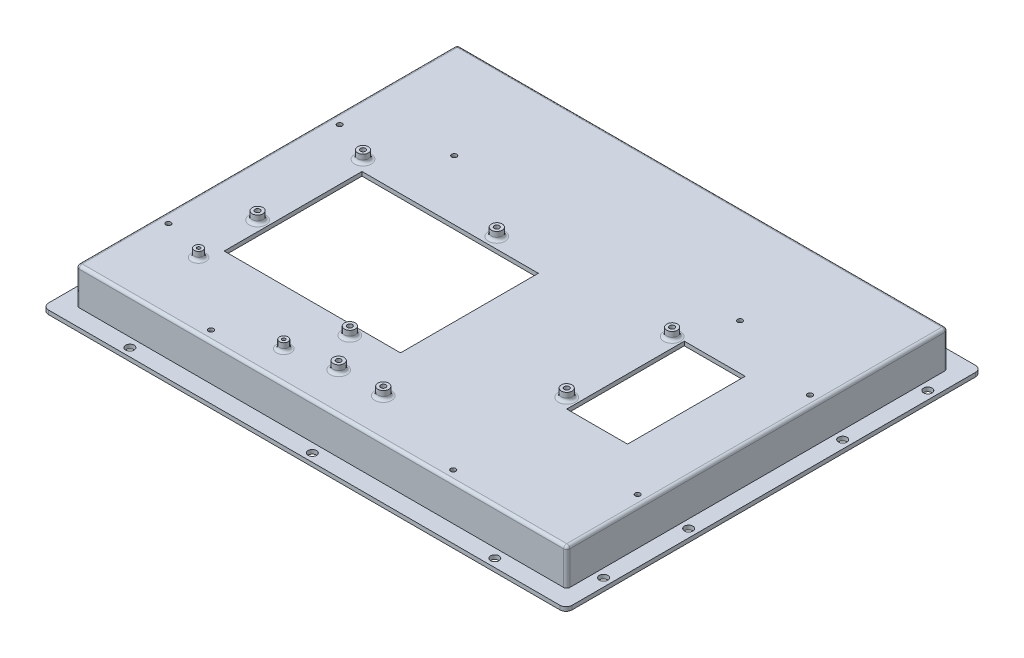
from build123d import *

# Parameters (mm, degrees)
SKETCH1_W                  = 258.3
SKETCH1_H                  = 205
BOSS_EXTRUDE1_DEPTH        = 20
SKETCH2_OUTSIDE_W          = 326.374
SKETCH2_OUTSIDE_H          = 273.074
SKETCH2_OUTSIDE_W_2        = 242
SKETCH2_OUTSIDE_H_2        = 188
CUT_EXTRUDE1_DEPTH         = 18
SKETCH3_W                  = 238
SKETCH3_H                  = 184
CUT_EXTRUDE2_DEPTH         = 18
SKETCH4_W                  = 87
SKETCH4_H                  = 68
SKETCH4_W_2                = 30
SKETCH4_H_2                = 58
CUT_EXTRUDE3_DEPTH         = 21
SKETCH5_R                  = 2.65
BOSS_EXTRUDE2_DEPTH        = 4
SKETCH6_R                  = 1.25
CUT_EXTRUDE4_DEPTH         = 25
SKETCH7_R                  = 2.1
CUT_EXTRUDE5_DEPTH         = 3
SKETCH8_R                  = 1.25
CUT_EXTRUDE6_DEPTH         = 21
SKETCH9_R                  = 3
SKETCH9_R_2                = 1.25
BOSS_EXTRUDE5_DEPTH        = 2
BOSS_EXTRUDE5_DEPTH_BACK   = 1
BOSS_EXTRUDE5_2_DEPTH      = 2
BOSS_EXTRUDE5_2_DEPTH_BACK = 1
BOSS_EXTRUDE5_3_DEPTH      = 2
BOSS_EXTRUDE5_3_DEPTH_BACK = 1
BOSS_EXTRUDE5_4_DEPTH      = 2
BOSS_EXTRUDE5_4_DEPTH_BACK = 1
BOSS_EXTRUDE5_5_DEPTH      = 2
BOSS_EXTRUDE5_5_DEPTH_BACK = 1
BOSS_EXTRUDE5_6_DEPTH      = 2
BOSS_EXTRUDE5_6_DEPTH_BACK = 1
BOSS_EXTRUDE5_7_DEPTH      = 2
BOSS_EXTRUDE5_7_DEPTH_BACK = 1
BOSS_EXTRUDE5_8_DEPTH      = 2
BOSS_EXTRUDE5_8_DEPTH_BACK = 1
SKETCH10_W                 = 12
SKETCH10_H                 = 15
SKETCH10_W_2               = 20
SKETCH10_H_2               = 12
SKETCH10_W_3               = 35
SKETCH10_W_4               = 10
SKETCH10_H_3               = 9.75
BOSS_EXTRUDE6_DEPTH        = 5
SKETCH11_W                 = 241.8
SKETCH11_H                 = 188.8
BOSS_EXTRUDE7_DEPTH        = 2
SKETCH12_W                 = 225
SKETCH12_H                 = 173.5
CUT_EXTRUDE7_DEPTH         = 2
SKETCH13_W                 = 61.997386765
SKETCH13_H                 = 3
SKETCH13_W_2               = 12
CUT_EXTRUDE8_DEPTH         = 0.25
SKETCH14_W                 = 20
SKETCH14_H                 = 3
SKETCH14_W_2               = 12
CUT_EXTRUDE9_DEPTH         = 0.25
SKETCH15_W                 = 5.5
SKETCH15_H                 = 10.3
CUT_EXTRUDE10_DEPTH        = 1.4
SKETCH16_W                 = 8.4
SKETCH16_H                 = 50
CUT_EXTRUDE11_DEPTH        = 2
SKETCH17_R                 = 2.1
BOSS_EXTRUDE8_DEPTH        = 4
SKETCH18_R                 = 0.8
CUT_EXTRUDE12_DEPTH        = 27
SKETCH19_W                 = 225
SKETCH19_H                 = 173.5
CUT_EXTRUDE13_DEPTH        = 1.7
FILLET1_R                  = 1
FILLET2_R                  = 1.5
FILLET3_R                  = 3


with BuildPart() as part:
    # Sketch1 → Boss-Extrude1 (new body)
    with BuildSketch(Plane(origin=(0, 0, 0), x_dir=(1, 0, 0), z_dir=(0, 1, 0))):
        with Locations((129.15, 102.5)):
            Rectangle(SKETCH1_W, SKETCH1_H)
    extrude(amount=BOSS_EXTRUDE1_DEPTH)

    # Sketch2 outside → Cut-Extrude1 (cut)
    with BuildSketch(Plane(origin=(0, 20, 0), x_dir=(-1, 0, 0), z_dir=(0, 1, 0))):
        with Locations((-129.15, -102.5)):
            Rectangle(SKETCH2_OUTSIDE_W, SKETCH2_OUTSIDE_H)
        with Locations((-129.15, -102.5)):
            Rectangle(SKETCH2_OUTSIDE_W_2, SKETCH2_OUTSIDE_H_2, mode=Mode.SUBTRACT)
    extrude(amount=-CUT_EXTRUDE1_DEPTH, mode=Mode.SUBTRACT)

    # Sketch3 → Cut-Extrude2 (cut)
    with BuildSketch(Plane.XZ):
        with Locations((129.15, -102.5)):
            Rectangle(SKETCH3_W, SKETCH3_H)
    extrude(amount=-CUT_EXTRUDE2_DEPTH, mode=Mode.SUBTRACT)

    # Sketch4 → Cut-Extrude3 (cut, through all)
    with BuildSketch(Plane(origin=(0, 20, 0), x_dir=(1, 0, 0), z_dir=(0, 1, 0))):
        with Locations((82.65, 84.5)):
            Rectangle(SKETCH4_W, SKETCH4_H)
        with Locations((206.15, 96.5)):
            Rectangle(SKETCH4_W_2, SKETCH4_H_2)
    extrude(amount=-CUT_EXTRUDE3_DEPTH, mode=Mode.SUBTRACT)

    # Sketch5 → Boss-Extrude2 (add)
    with BuildSketch(Plane(origin=(0, 20, 0), x_dir=(1, 0, 0), z_dir=(0, 1, 0))):
        with Locations((34.15, 72)):
            Circle(SKETCH5_R)
        with Locations((34.15, 124)):
            Circle(SKETCH5_R)
        with Locations((100.15, 124)):
            Circle(SKETCH5_R)
        with Locations((106.15, 45.5)):
            Circle(SKETCH5_R)
        with Locations((186.15, 72.5)):
            Circle(SKETCH5_R)
        with Locations((186.15, 124.5)):
            Circle(SKETCH5_R)
        with Locations((118.15, 28)):
            Circle(SKETCH5_R)
        with Locations((140.15, 28)):
            Circle(SKETCH5_R)
    extrude(amount=BOSS_EXTRUDE2_DEPTH)

    # Sketch6 → Cut-Extrude4 (cut, through all)
    with BuildSketch(Plane(origin=(0, 24, 0), x_dir=(1, 0, 0), z_dir=(0, 1, 0))):
        with Locations((34.15, 124)):
            Circle(SKETCH6_R)
        with Locations((100.15, 124)):
            Circle(SKETCH6_R)
        with Locations((186.15, 124.5)):
            Circle(SKETCH6_R)
        with Locations((186.15, 72.5)):
            Circle(SKETCH6_R)
        with Locations((106.15, 45.5)):
            Circle(SKETCH6_R)
        with Locations((34.15, 72)):
            Circle(SKETCH6_R)
        with Locations((140.15, 28)):
            Circle(SKETCH6_R)
        with Locations((118.15, 28)):
            Circle(SKETCH6_R)
    extrude(amount=-CUT_EXTRUDE4_DEPTH, mode=Mode.SUBTRACT)

    # Sketch7 → Cut-Extrude5 (cut, through all)
    with BuildSketch(Plane(origin=(0, 2, 0), x_dir=(1, 0, 0), z_dir=(0, 1, 0))):
        with Locations((254.3, 22.5)):
            Circle(SKETCH7_R)
        with Locations((254.3, 140.5)):
            Circle(SKETCH7_R)
        with Locations((254.3, 182.5)):
            Circle(SKETCH7_R)
        with Locations((219.15, 201)):
            Circle(SKETCH7_R)
        with Locations((134.15, 201)):
            Circle(SKETCH7_R)
        with Locations((124.15, 201)):
            Circle(SKETCH7_R)
        with Locations((39.15, 201)):
            Circle(SKETCH7_R)
        with Locations((4, 182.5)):
            Circle(SKETCH7_R)
        with Locations((4, 102.5)):
            Circle(SKETCH7_R)
        with Locations((4, 22.5)):
            Circle(SKETCH7_R)
        with Locations((219.15, 4)):
            Circle(SKETCH7_R)
        with Locations((129.15, 4)):
            Circle(SKETCH7_R)
        with Locations((39.15, 4)):
            Circle(SKETCH7_R)
        with Locations((254.3, 64.5)):
            Circle(SKETCH7_R)
    extrude(amount=-CUT_EXTRUDE5_DEPTH, mode=Mode.SUBTRACT)

    # Sketch8 → Cut-Extrude6 (cut, through all)
    with BuildSketch(Plane(origin=(0, 20, 0), x_dir=(1, 0, 0), z_dir=(0, 1, 0))):
        with Locations((55.15, 148)):
            Circle(SKETCH8_R)
        with Locations((13.65, 133)):
            Circle(SKETCH8_R)
        with Locations((13.65, 48.5)):
            Circle(SKETCH8_R)
        with Locations((69.65, 13.5)):
            Circle(SKETCH8_R)
        with Locations((189.15, 13.5)):
            Circle(SKETCH8_R)
        with Locations((245.15, 48.5)):
            Circle(SKETCH8_R)
        with Locations((245.15, 133.5)):
            Circle(SKETCH8_R)
        with Locations((196.15, 148)):
            Circle(SKETCH8_R)
    extrude(amount=-CUT_EXTRUDE6_DEPTH, mode=Mode.SUBTRACT)

    # Sketch10 → Boss-Extrude6 (add)
    with BuildSketch(Plane.XZ):
        with Locations((14.15, -15.75)):
            Rectangle(SKETCH10_W, SKETCH10_H)
        with Locations((129.15, -14.25)):
            Rectangle(SKETCH10_W_2, SKETCH10_H_2)
        with Locations((244.15, -15.75)):
            Rectangle(SKETCH10_W, SKETCH10_H)
        with Locations((14.15, -189.25)):
            Rectangle(SKETCH10_W, SKETCH10_H)
        with Locations((163.65, -190.75)):
            Rectangle(SKETCH10_W_3, SKETCH10_H_2)
        with Locations((244.15, -189.25)):
            Rectangle(SKETCH10_W, SKETCH10_H)
        with Locations((15.15, -67.5)):
            Rectangle(SKETCH10_W_4, SKETCH10_H)
        with Locations((15.15, -137.5)):
            Rectangle(SKETCH10_W_4, SKETCH10_H)
        with Locations((243.15, -67.5)):
            Rectangle(SKETCH10_W_4, SKETCH10_H)
        with Locations((243.15, -137.5)):
            Rectangle(SKETCH10_W_4, SKETCH10_H)
        with Locations((66.65, -15.375)):
            Rectangle(SKETCH10_W_2, SKETCH10_H_3)
        with Locations((191.65, -15.375)):
            Rectangle(SKETCH10_W_2, SKETCH10_H_3)
        with Locations((94.65, -189.625)):
            Rectangle(SKETCH10_W_3, SKETCH10_H_3)
        with Locations((224.15, -189.625)):
            Rectangle(SKETCH10_W, SKETCH10_H_3)
        with Locations((34.15, -189.625)):
            Rectangle(SKETCH10_W, SKETCH10_H_3)
    extrude(amount=-BOSS_EXTRUDE6_DEPTH)

    # Sketch11 → Boss-Extrude7 (add)
    with BuildSketch(Plane.XZ):
        with Locations((129.15, -102.5)):
            Rectangle(SKETCH11_W, SKETCH11_H)
    extrude(amount=BOSS_EXTRUDE7_DEPTH)

    # Sketch12 → Cut-Extrude7 (cut)
    with BuildSketch(Plane.XZ.offset(2)):
        with Locations((129.15, -102.5)):
            Rectangle(SKETCH12_W, SKETCH12_H)
    extrude(amount=-CUT_EXTRUDE7_DEPTH, mode=Mode.SUBTRACT)

    # Sketch13 → Cut-Extrude8 (cut)
    with BuildSketch(Plane(origin=(0, 0, -196.75), x_dir=(-1, 0, 0), z_dir=(0, 0, -1))):
        with Locations((-150.151306618, 3.5)):
            Rectangle(SKETCH13_W, SKETCH13_H)
        with Locations((-14.15, 3.5)):
            Rectangle(SKETCH13_W_2, SKETCH13_H)
        with Locations((-244.15, 3.5)):
            Rectangle(SKETCH13_W_2, SKETCH13_H)
    extrude(amount=-CUT_EXTRUDE8_DEPTH, mode=Mode.SUBTRACT)

    # Sketch14 → Cut-Extrude9 (cut)
    with BuildSketch(Plane.XY.offset(-8.25)):
        with Locations((129.15, 3.5)):
            Rectangle(SKETCH14_W, SKETCH14_H)
        with Locations((244.15, 3.5)):
            Rectangle(SKETCH14_W_2, SKETCH14_H)
        with Locations((14.15, 3.5)):
            Rectangle(SKETCH14_W_2, SKETCH14_H)
    extrude(amount=-CUT_EXTRUDE9_DEPTH, mode=Mode.SUBTRACT)

    # Sketch15 → Cut-Extrude10 (cut)
    with BuildSketch(Plane.XZ.offset(2)):
        with Locations((13.9, -38.9)):
            Rectangle(SKETCH15_W, SKETCH15_H)
        with Locations((13.9, -166.1)):
            Rectangle(SKETCH15_W, SKETCH15_H)
        with Locations((244.4, -166.1)):
            Rectangle(SKETCH15_W, SKETCH15_H)
        with Locations((244.4, -38.9)):
            Rectangle(SKETCH15_W, SKETCH15_H)
    extrude(amount=-CUT_EXTRUDE10_DEPTH, mode=Mode.SUBTRACT)

    # Sketch16 → Cut-Extrude11 (cut)
    with BuildSketch(Plane.XZ.offset(2)):
        with Locations((12.45, -102.5)):
            Rectangle(SKETCH16_W, SKETCH16_H)
    extrude(amount=-CUT_EXTRUDE11_DEPTH, mode=Mode.SUBTRACT)

    # Sketch17 → Boss-Extrude8 (add)
    with BuildSketch(Plane(origin=(0, 20, 0), x_dir=(1, 0, 0), z_dir=(0, 1, 0))):
        with Locations((35.55, 41.5)):
            Circle(SKETCH17_R)
        with Locations((95.55, 23.5)):
            Circle(SKETCH17_R)
    extrude(amount=BOSS_EXTRUDE8_DEPTH)

    # Sketch18 → Cut-Extrude12 (cut, through all)
    with BuildSketch(Plane(origin=(0, 24, 0), x_dir=(1, 0, 0), z_dir=(0, 1, 0))):
        with Locations((35.55, 41.5)):
            Circle(SKETCH18_R)
        with Locations((95.55, 23.5)):
            Circle(SKETCH18_R)
    extrude(amount=-CUT_EXTRUDE12_DEPTH, mode=Mode.SUBTRACT)

    # Sketch19 → Cut-Extrude13 (cut)
    with BuildSketch(Plane.XZ):
        with Locations((129.15, -102.5)):
            Rectangle(SKETCH19_W, SKETCH19_H)
    extrude(amount=-CUT_EXTRUDE13_DEPTH, mode=Mode.SUBTRACT)

    # Fillet1
    fillet1_edges = [part.edges().sort_by_distance(p)[0] for p in [
        (248.15, 18, -102.5),
        (248.15, 11.5, -10.5),
        (129.15, 18, -194.5),
        (248.15, 11.5, -194.5),
        (10.15, 18, -102.5),
        (10.15, 11.5, -194.5),
        (129.15, 18, -10.5),
        (10.15, 11.5, -10.5),
        (8.25, -1, -8.1),
        (8.25, -1, -196.9),
        (250.05, -1, -196.9),
        (250.05, -1, -8.1),
    ]]
    fillet(fillet1_edges, radius=FILLET1_R)

    # Fillet2
    fillet2_edges = [part.edges().sort_by_distance(p)[0] for p in [
        (97.5, 20, -124),
        (103.5, 20, -45.5),
        (183.5, 20, -72.5),
        (183.5, 20, -124.5),
        (115.5, 20, -28),
        (137.5, 20, -28),
        (8.15, 20, -102.5),
        (129.15, 20, -196.5),
        (250.15, 20, -102.5),
        (129.15, 20, -8.5),
        (8.15, 11, -8.5),
        (250.15, 11, -8.5),
        (8.15, 11, -196.5),
        (250.15, 11, -196.5),
        (33.45, 20, -41.5),
        (93.45, 20, -23.5),
        (31.5, 20, -72),
        (31.5, 20, -124),
    ]]
    fillet(fillet2_edges, radius=FILLET2_R)

    # Fillet3
    fillet3_edges = [part.edges().sort_by_distance(p)[0] for p in [
        (0, 1, -205),
        (258.3, 1, -205),
        (258.3, 1, 0),
        (0, 1, 0),
    ]]
    fillet(fillet3_edges, radius=FILLET3_R)


with BuildPart() as body_2:
    # Sketch9 → Boss-Extrude5 (new body, two sides)
    with BuildSketch(Plane.XZ.offset(-18)) as boss_extrude5_sk:
        with Locations((13.65, -48.5)):
            Circle(SKETCH9_R)
        with Locations((13.65, -48.5)):
            Circle(SKETCH9_R_2, mode=Mode.SUBTRACT)
    extrude(amount=BOSS_EXTRUDE5_DEPTH)
    extrude(boss_extrude5_sk.sketch, amount=-BOSS_EXTRUDE5_DEPTH_BACK)


with BuildPart() as body_3:
    # Sketch9 → Boss-Extrude5 2 (new body, two sides)
    with BuildSketch(Plane.XZ.offset(-18)) as boss_extrude5_2_sk:
        with Locations((69.65, -13.5)):
            Circle(SKETCH9_R)
        with Locations((69.65, -13.5)):
            Circle(SKETCH9_R_2, mode=Mode.SUBTRACT)
    extrude(amount=BOSS_EXTRUDE5_2_DEPTH)
    extrude(boss_extrude5_2_sk.sketch, amount=-BOSS_EXTRUDE5_2_DEPTH_BACK)


with BuildPart() as body_4:
    # Sketch9 → Boss-Extrude5 3 (new body, two sides)
    with BuildSketch(Plane.XZ.offset(-18)) as boss_extrude5_3_sk:
        with Locations((189.15, -13.5)):
            Circle(SKETCH9_R)
        with Locations((189.15, -13.5)):
            Circle(SKETCH9_R_2, mode=Mode.SUBTRACT)
    extrude(amount=BOSS_EXTRUDE5_3_DEPTH)
    extrude(boss_extrude5_3_sk.sketch, amount=-BOSS_EXTRUDE5_3_DEPTH_BACK)


with BuildPart() as body_5:
    # Sketch9 → Boss-Extrude5 4 (new body, two sides)
    with BuildSketch(Plane.XZ.offset(-18)) as boss_extrude5_4_sk:
        with Locations((245.15, -48.5)):
            Circle(SKETCH9_R)
        with Locations((245.15, -48.5)):
            Circle(SKETCH9_R_2, mode=Mode.SUBTRACT)
    extrude(amount=BOSS_EXTRUDE5_4_DEPTH)
    extrude(boss_extrude5_4_sk.sketch, amount=-BOSS_EXTRUDE5_4_DEPTH_BACK)


with BuildPart() as body_6:
    # Sketch9 → Boss-Extrude5 5 (new body, two sides)
    with BuildSketch(Plane.XZ.offset(-18)) as boss_extrude5_5_sk:
        with Locations((245.15, -133.5)):
            Circle(SKETCH9_R)
        with Locations((245.15, -133.5)):
            Circle(SKETCH9_R_2, mode=Mode.SUBTRACT)
    extrude(amount=BOSS_EXTRUDE5_5_DEPTH)
    extrude(boss_extrude5_5_sk.sketch, amount=-BOSS_EXTRUDE5_5_DEPTH_BACK)


with BuildPart() as body_7:
    # Sketch9 → Boss-Extrude5 6 (new body, two sides)
    with BuildSketch(Plane.XZ.offset(-18)) as boss_extrude5_6_sk:
        with Locations((196.15, -148)):
            Circle(SKETCH9_R)
        with Locations((196.15, -148)):
            Circle(SKETCH9_R_2, mode=Mode.SUBTRACT)
    extrude(amount=BOSS_EXTRUDE5_6_DEPTH)
    extrude(boss_extrude5_6_sk.sketch, amount=-BOSS_EXTRUDE5_6_DEPTH_BACK)


with BuildPart() as body_8:
    # Sketch9 → Boss-Extrude5 7 (new body, two sides)
    with BuildSketch(Plane.XZ.offset(-18)) as boss_extrude5_7_sk:
        with Locations((55.15, -148)):
            Circle(SKETCH9_R)
        with Locations((55.15, -148)):
            Circle(SKETCH9_R_2, mode=Mode.SUBTRACT)
    extrude(amount=BOSS_EXTRUDE5_7_DEPTH)
    extrude(boss_extrude5_7_sk.sketch, amount=-BOSS_EXTRUDE5_7_DEPTH_BACK)


with BuildPart() as body_9:
    # Sketch9 → Boss-Extrude5 8 (new body, two sides)
    with BuildSketch(Plane.XZ.offset(-18)) as boss_extrude5_8_sk:
        with Locations((13.65, -133)):
            Circle(SKETCH9_R)
        with Locations((13.65, -133)):
            Circle(SKETCH9_R_2, mode=Mode.SUBTRACT)
    extrude(amount=BOSS_EXTRUDE5_8_DEPTH)
    extrude(boss_extrude5_8_sk.sketch, amount=-BOSS_EXTRUDE5_8_DEPTH_BACK)


solid = Compound([part.part, body_2.part, body_3.part, body_4.part, body_5.part, body_6.part, body_7.part, body_8.part, body_9.part])
